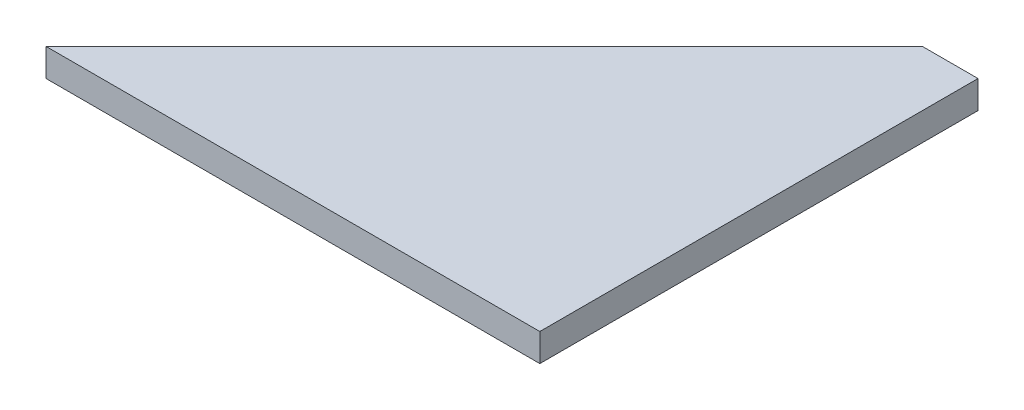
from build123d import *

# Parameters (mm, degrees)
BOSS_EXTRUDE1_DEPTH = 3.175
SKETCH2_W           = 50
SKETCH2_H           = 3.175
BOSS_EXTRUDE2_DEPTH = 6.35


with BuildPart() as part:
    # Sketch1 → Boss-Extrude1 (new body)
    with BuildSketch(Plane(origin=(0, 0, 0), x_dir=(1, 0, 0), z_dir=(0, 1, 0))):
        Polygon((0, 0), (50, 50), (50, 0), align=None)
    extrude(amount=BOSS_EXTRUDE1_DEPTH)

    # Sketch2 → Boss-Extrude2 (add)
    with BuildSketch(Plane(origin=(50, 0, 0), x_dir=(0, 0, -1), z_dir=(1, 0, 0))):
        with Locations((25, 1.5875)):
            Rectangle(SKETCH2_W, SKETCH2_H)
    extrude(amount=BOSS_EXTRUDE2_DEPTH)


solid = part.part
